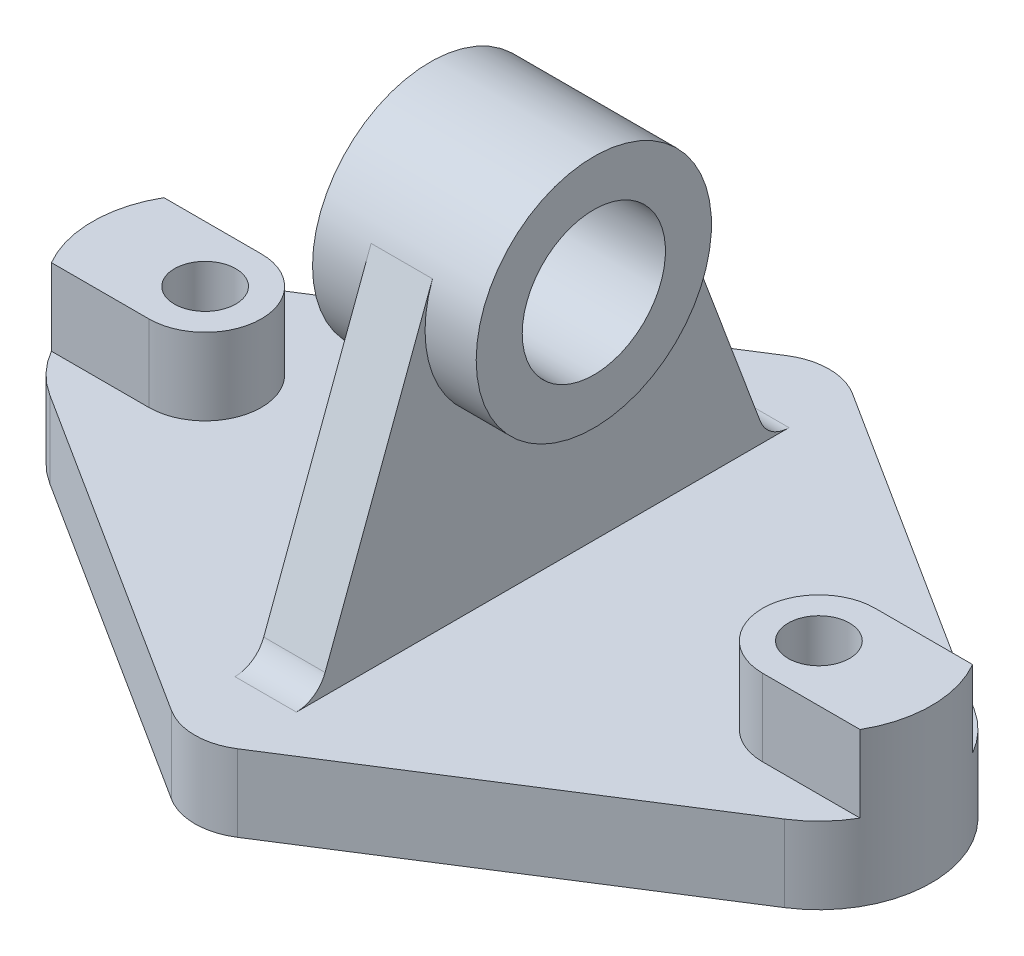
from build123d import *

# Parameters (mm, degrees)
SKETCH1_R           = 6
BOSS_EXTRUDE1_DEPTH = 30
BOSS_EXTRUDE2_DEPTH = 15
BOSS_EXTRUDE3_DEPTH = 6
SKETCH2_3_R         = 14
BOSS_EXTRUDE4_DEPTH = 16
FILLET1_R           = 6


with BuildPart() as part:
    # Sketch1 → Boss-Extrude1 (new body)
    with BuildSketch(Plane(origin=(0, 0, 0), x_dir=(1, 0, 0), z_dir=(0, 1, 0))):
        with BuildLine():
            ThreePointArc((60, 11), (49, 0), (60, -11))
            Line((60, -11), (79.052558883, -11))
            ThreePointArc((79.052558883, -11), (82, 0), (79.052558883, 11))
            Line((79.052558883, 11), (60, 11))
        make_face()
        with Locations((60, 0)):
            Circle(SKETCH1_R, mode=Mode.SUBTRACT)
    extrude(amount=BOSS_EXTRUDE1_DEPTH)

    # Sketch1_3 → Boss-Extrude2 (add)
    with BuildSketch(Plane(origin=(0, 0, 0), x_dir=(1, 0, 0), z_dir=(0, 1, 0))):
        with BuildLine():
            ThreePointArc((6.438655763, 60.126386916), (3.352861242, 61.522079738), (0, 62))
            Line((0, 62), (0, -62))
            ThreePointArc((0, -62), (3.352861242, -61.522079738), (6.438655763, -60.126386916))
            Line((6.438655763, -60.126386916), (71.804202232, -18.565042679))
            ThreePointArc((71.804202232, -18.565042679), (75.885288613, -15.220302418), (79.052558883, -11))
            Line((79.052558883, -11), (60, -11))
            ThreePointArc((60, -11), (49, 0), (60, 11))
            Line((60, 11), (79.052558883, 11))
            ThreePointArc((79.052558883, 11), (75.885288613, 15.220302418), (71.804202232, 18.565042679))
            Line((71.804202232, 18.565042679), (6.438655763, 60.126386916))
        make_face()
    extrude(amount=BOSS_EXTRUDE2_DEPTH)

    # Sketch2 → Boss-Extrude3 (add)
    with BuildSketch(Plane.ZY):
        with BuildLine():
            Line((-44, 15), (44, 15))
            Line((44, 15), (21.543109519, 75.055708054))
            ThreePointArc((21.543109519, 75.055708054), (0, 44), (-21.543109519, 75.055708054))
            Line((-21.543109519, 75.055708054), (-44, 15))
        make_face()
    extrude(amount=-BOSS_EXTRUDE3_DEPTH)

    # Sketch2_3 → Boss-Extrude4 (add)
    with BuildSketch(Plane.ZY):
        with BuildLine():
            ThreePointArc((23, 67), (22.632846915, 71.093194417), (21.543109519, 75.055708054))
            ThreePointArc((21.543109519, 75.055708054), (0, 90), (-21.543109519, 75.055708054))
            ThreePointArc((-21.543109519, 75.055708054), (-4.093194417, 44.367153085), (23, 67))
        make_face()
        with Locations((0, 67)):
            Circle(SKETCH2_3_R, mode=Mode.SUBTRACT)
    extrude(amount=-BOSS_EXTRUDE4_DEPTH)

    # Fillet1
    fillet1_edges = [part.edges().sort_by_distance(p)[0] for p in [
        (3, 15, -44),
        (3, 15, 44),
    ]]
    fillet(fillet1_edges, radius=FILLET1_R)

    # Mirror1: part across plane


with BuildPart() as part_1:
    add(part.part)
    add(part.part.mirror(Plane(origin=(0, 15, 0), x_dir=(0, 0, 1), z_dir=(1, 0, 0))))


solid = part_1.part
